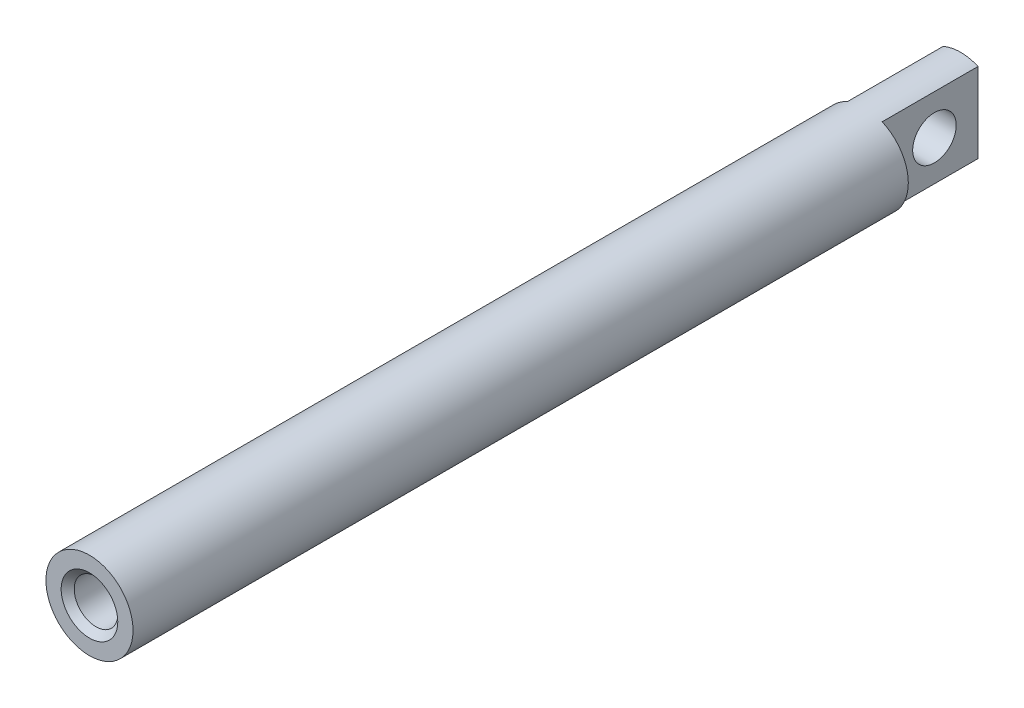
from build123d import *

# Parameters (mm, degrees)
SKETCH1_R                       = 5
BOSS_EXTRUDE1_DEPTH             = 100
CUT_EXTRUDE5_REACH              = 7
SKETCH2_W                       = 3
SKETCH2_H                       = 11
CUT_EXTRUDE5_DIRECTION_2_REACH  = 7
CUT_EXTRUDE6_REACH              = 9
SKETCH3_R                       = 2.5
M6X1_0_TAPPED_HOLE1_D           = 5
M6X1_0_TAPPED_HOLE1_DEPTH       = 17
M6X1_0_TAPPED_HOLE1_CSINK_D     = 6.5
M6X1_0_TAPPED_HOLE1_CSINK_ANGLE = 90
M6X1_0_TAPPED_HOLE1_TIP         = 1.502151548


with BuildPart() as part:
    # Sketch1 → Boss-Extrude1 (new body)
    with BuildSketch(Plane.XY):
        Circle(SKETCH1_R)
    extrude(amount=-BOSS_EXTRUDE1_DEPTH)

    # Sketch2 → Cut-Extrude5 (cut, up to next)
    with BuildSketch(Plane(origin=(0, 0, 0), x_dir=(1, 0, 0), z_dir=(0, 1, 0)), mode=Mode.PRIVATE) as cut_extrude5_sk1:
        with Locations((-3.5, 94.5)):
            Rectangle(SKETCH2_W, SKETCH2_H)
    cut_extrude5_tool1 = extrude(cut_extrude5_sk1.sketch, amount=-CUT_EXTRUDE5_REACH, mode=Mode.PRIVATE) & part.part
    add(cut_extrude5_tool1.solids().sort_by_distance((-3.5, 0, -94.5))[0], mode=Mode.SUBTRACT)
    # Sketch2 → Cut-Extrude5 (cut, up to next)
    with BuildSketch(Plane(origin=(0, 0, 0), x_dir=(1, 0, 0), z_dir=(0, 1, 0)), mode=Mode.PRIVATE) as cut_extrude5_sk2:
        with Locations((3.5, 94.5)):
            Rectangle(SKETCH2_W, SKETCH2_H)
    cut_extrude5_tool2 = extrude(cut_extrude5_sk2.sketch, amount=-CUT_EXTRUDE5_REACH, mode=Mode.PRIVATE) & part.part
    add(cut_extrude5_tool2.solids().sort_by_distance((3.5, 0, -94.5))[0], mode=Mode.SUBTRACT)

    # Sketch2 → Cut-Extrude5 direction 2 (cut, up to next)
    with BuildSketch(Plane(origin=(0, 0, 0), x_dir=(1, 0, 0), z_dir=(0, 1, 0)), mode=Mode.PRIVATE) as cut_extrude5_direction_2_sk1:
        with Locations((-3.5, 94.5)):
            Rectangle(SKETCH2_W, SKETCH2_H)
    cut_extrude5_direction_2_tool1 = extrude(cut_extrude5_direction_2_sk1.sketch, amount=CUT_EXTRUDE5_DIRECTION_2_REACH, mode=Mode.PRIVATE) & part.part
    add(cut_extrude5_direction_2_tool1.solids().sort_by_distance((-3.5, 0, -94.5))[0], mode=Mode.SUBTRACT)
    # Sketch2 → Cut-Extrude5 direction 2 (cut, up to next)
    with BuildSketch(Plane(origin=(0, 0, 0), x_dir=(1, 0, 0), z_dir=(0, 1, 0)), mode=Mode.PRIVATE) as cut_extrude5_direction_2_sk2:
        with Locations((3.5, 94.5)):
            Rectangle(SKETCH2_W, SKETCH2_H)
    cut_extrude5_direction_2_tool2 = extrude(cut_extrude5_direction_2_sk2.sketch, amount=CUT_EXTRUDE5_DIRECTION_2_REACH, mode=Mode.PRIVATE) & part.part
    add(cut_extrude5_direction_2_tool2.solids().sort_by_distance((3.5, 0, -94.5))[0], mode=Mode.SUBTRACT)

    # Sketch3 → Cut-Extrude6 (cut, up to next)
    with BuildSketch(Plane(origin=(2, 0, 0), x_dir=(0, 0, -1), z_dir=(1, 0, 0)), mode=Mode.PRIVATE) as cut_extrude6_sk1:
        with Locations((95, 0)):
            Circle(SKETCH3_R)
    cut_extrude6_tool1 = extrude(cut_extrude6_sk1.sketch, amount=-CUT_EXTRUDE6_REACH, mode=Mode.PRIVATE) & part.part
    add(cut_extrude6_tool1.solids().sort_by_distance((2, 0, -95))[0], mode=Mode.SUBTRACT)

    # M6x1.0 Tapped Hole1
    with Locations(Plane.XY):
        with Locations((0, 0)):
            CounterSinkHole(M6X1_0_TAPPED_HOLE1_D / 2, M6X1_0_TAPPED_HOLE1_CSINK_D / 2, depth=M6X1_0_TAPPED_HOLE1_DEPTH, counter_sink_angle=M6X1_0_TAPPED_HOLE1_CSINK_ANGLE)
            with Locations((0, 0, -(M6X1_0_TAPPED_HOLE1_DEPTH + M6X1_0_TAPPED_HOLE1_TIP / 2))):  # 118° drill point
                Cone(0, M6X1_0_TAPPED_HOLE1_D / 2, M6X1_0_TAPPED_HOLE1_TIP, mode=Mode.SUBTRACT)


solid = part.part
